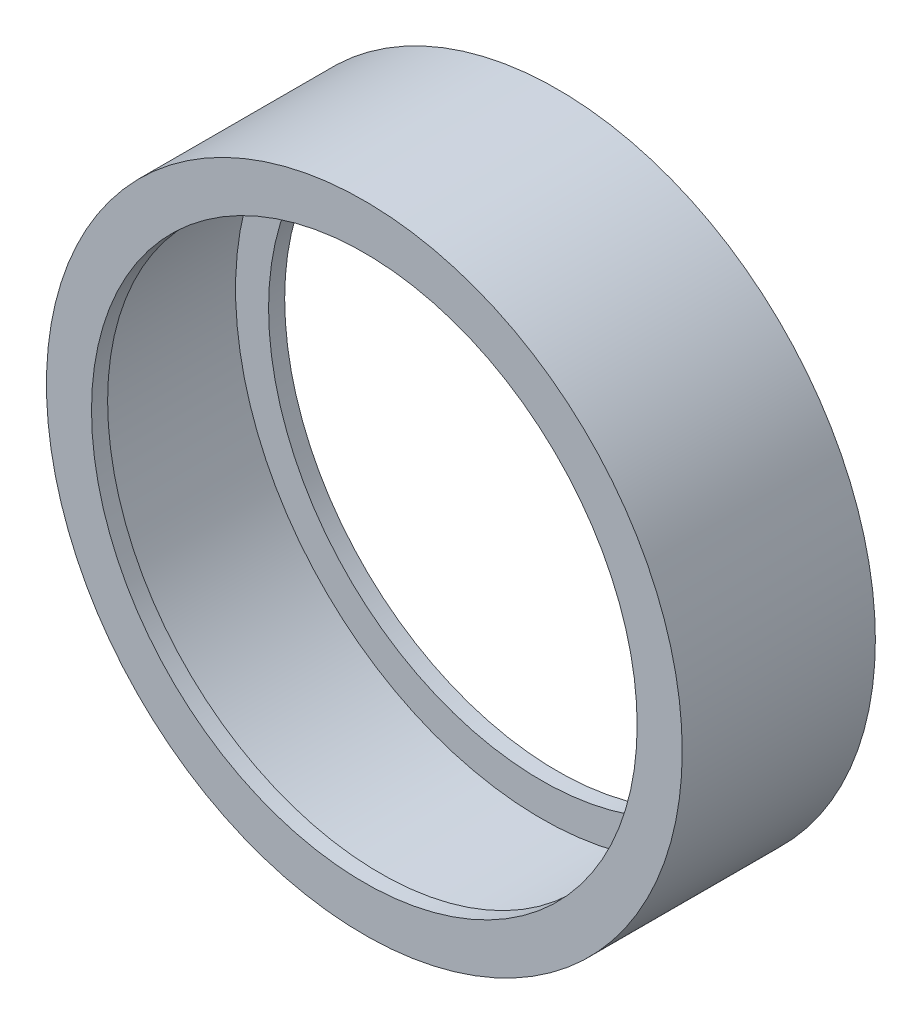
from build123d import *

# Parameters (mm, degrees)
SKETCH2_R           = 8.6106
BOSS_EXTRUDE1_DEPTH = 4.064
SKETCH3_R           = 10.033
BOSS_EXTRUDE2_DEPTH = 5.08
SKETCH4_R           = 8.6106
CUT_EXTRUDE1_DEPTH  = 6.08
SKETCH9_R           = 10.033
SKETCH9_R_2         = 8.128
BOSS_EXTRUDE3_DEPTH = 0.508
SKETCH10_R          = 10.033
SKETCH10_R_2        = 8.128
BOSS_EXTRUDE4_DEPTH = 0.508
SKETCH12_R          = 9.271
CUT_EXTRUDE2_DEPTH  = 7.096
SKETCH13_R          = 10.033
CUT_EXTRUDE3_DEPTH  = 0.508
SKETCH15_R          = 10.033
SKETCH15_R_2        = 9.271
CUT_EXTRUDE4_DEPTH  = 0.508
SKETCH16_R          = 9.652
SKETCH16_R_2        = 9.271
CUT_EXTRUDE5_DEPTH  = 6.08
SKETCH17_R          = 10.033
SKETCH17_R_2        = 8.6106
BOSS_EXTRUDE5_DEPTH = 0.508
SKETCH18_R          = 10.033
SKETCH18_R_2        = 8.6106
BOSS_EXTRUDE6_DEPTH = 0.508
SCALE1_SCALE        = 0.5


with BuildPart() as part:
    # Sketch2 → Boss-Extrude1 (new body)
    with BuildSketch(Plane.XY):
        Circle(SKETCH2_R)
    extrude(amount=-BOSS_EXTRUDE1_DEPTH)

    # Sketch3 → Boss-Extrude2 (add)
    with BuildSketch(Plane.XY):
        Circle(SKETCH3_R)
    extrude(amount=-BOSS_EXTRUDE2_DEPTH)

    # Sketch4 → Cut-Extrude1 (cut, through all)
    with BuildSketch(Plane.XY):
        Circle(SKETCH4_R)
    extrude(amount=-CUT_EXTRUDE1_DEPTH, mode=Mode.SUBTRACT)

    # Sketch9 → Boss-Extrude3 (add)
    with BuildSketch(Plane.XY):
        Circle(SKETCH9_R)
        Circle(SKETCH9_R_2, mode=Mode.SUBTRACT)
    extrude(amount=BOSS_EXTRUDE3_DEPTH)

    # Sketch10 → Boss-Extrude4 (add)
    with BuildSketch(Plane(origin=(0, 0, -5.08), x_dir=(-1, 0, 0), z_dir=(0, 0, -1))):
        Circle(SKETCH10_R)
        Circle(SKETCH10_R_2, mode=Mode.SUBTRACT)
    extrude(amount=BOSS_EXTRUDE4_DEPTH)

    # Sketch12 → Cut-Extrude2 (cut, through all)
    with BuildSketch(Plane(origin=(0, 0, -5.588), x_dir=(-1, 0, 0), z_dir=(0, 0, -1))):
        Circle(SKETCH12_R)
    extrude(amount=-CUT_EXTRUDE2_DEPTH, mode=Mode.SUBTRACT)

    # Sketch13 → Cut-Extrude3 (cut)
    with BuildSketch(Plane(origin=(0, 0, -5.588), x_dir=(-1, 0, 0), z_dir=(0, 0, -1))):
        Circle(SKETCH13_R)
    extrude(amount=-CUT_EXTRUDE3_DEPTH, mode=Mode.SUBTRACT)

    # Sketch15 → Cut-Extrude4 (cut)
    with BuildSketch(Plane.XY.offset(0.508)):
        Circle(SKETCH15_R)
        Circle(SKETCH15_R_2, mode=Mode.SUBTRACT)
    extrude(amount=-CUT_EXTRUDE4_DEPTH, mode=Mode.SUBTRACT)

    # Sketch16 → Cut-Extrude5 (cut, through all)
    with BuildSketch(Plane.XY):
        Circle(SKETCH16_R)
        Circle(SKETCH16_R_2, mode=Mode.SUBTRACT)
    extrude(amount=-CUT_EXTRUDE5_DEPTH, mode=Mode.SUBTRACT)

    # Sketch17 → Boss-Extrude5 (add)
    with BuildSketch(Plane.XY):
        Circle(SKETCH17_R)
        Circle(SKETCH17_R_2, mode=Mode.SUBTRACT)
    extrude(amount=BOSS_EXTRUDE5_DEPTH)

    # Sketch18 → Boss-Extrude6 (add)
    with BuildSketch(Plane(origin=(0, 0, -5.08), x_dir=(-1, 0, 0), z_dir=(0, 0, -1))):
        Circle(SKETCH18_R)
        Circle(SKETCH18_R_2, mode=Mode.SUBTRACT)
    extrude(amount=BOSS_EXTRUDE6_DEPTH)


with BuildPart() as part_1:
    # Scale1: scaled about (0, 0, -2.54)
    add(part.part.scale(SCALE1_SCALE).moved(Location((0, 0, -1.27))))


solid = part_1.part
